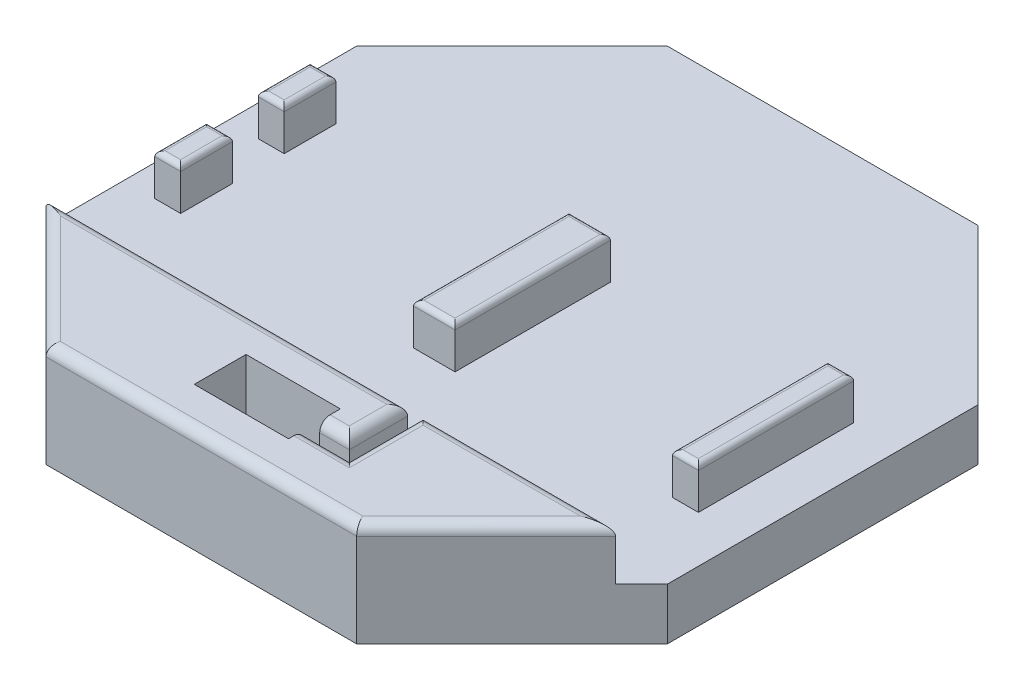
from build123d import *

# Parameters (mm, degrees)
BOSS_EXTRUDE1_DEPTH = 12.7
SKETCH2_W           = 10.16
SKETCH2_H           = 38.1
SKETCH2_W_2         = 6.35
SKETCH2_H_2         = 12.7
BOSS_EXTRUDE2_DEPTH = 10.16
BOSS_EXTRUDE3_DEPTH = 12.7
CUT_EXTRUDE1_DEPTH  = 15.24
FILLET2_R           = 2.54
FILLET4_R           = 1.27
BOSS_EXTRUDE4_DEPTH = 3.81


with BuildPart() as part:
    # Sketch1 → Boss-Extrude1 (new body)
    with BuildSketch(Plane(origin=(0, 0, 0), x_dir=(1, 0, 0), z_dir=(0, 1, 0))):
        Polygon((-38.1, 76.2), (38.1, 76.2), (76.2, 38.1), (76.2, -38.1), (38.1, -76.2), (-38.1, -76.2), (-76.2, -38.1), (-76.2, 38.1), align=None)
    extrude(amount=BOSS_EXTRUDE1_DEPTH)

    # Sketch2 → Boss-Extrude2 (add)
    with BuildSketch(Plane(origin=(0, 12.7, 0), x_dir=(1, 0, 0), z_dir=(0, 1, 0))):
        Rectangle(SKETCH2_W, SKETCH2_H)
        with Locations((61.595, 0)):
            Rectangle(SKETCH2_W_2, SKETCH2_H)
        with Locations((-65.405, 12.7)):
            Rectangle(SKETCH2_W_2, SKETCH2_H_2)
        with Locations((-65.405, -12.7)):
            Rectangle(SKETCH2_W_2, SKETCH2_H_2)
    extrude(amount=BOSS_EXTRUDE2_DEPTH)

    # Sketch4 → Boss-Extrude3 (add)
    with BuildSketch(Plane(origin=(0, 12.7, 0), x_dir=(1, 0, 0), z_dir=(0, 1, 0))):
        Polygon((-69.85, -44.45), (69.85, -44.45), (38.1, -76.2), (-38.1, -76.2), align=None)
    extrude(amount=BOSS_EXTRUDE3_DEPTH)

    # Sketch5 → Cut-Extrude1 (cut)
    with BuildSketch(Plane(origin=(0, 25.4, 0), x_dir=(1, 0, 0), z_dir=(0, 1, 0))):
        Polygon((11.557, -58.721300535), (18.829335275, -58.721300535), (18.829335275, -44.45), (22.639335275, -44.45), (22.639335275, -62.531300535), (11.557, -62.531300535), (11.557, -66.37376468), (-11.557, -66.37376468), (-11.557, -53.67376468), (11.557, -53.67376468), align=None)
    extrude(amount=-CUT_EXTRUDE1_DEPTH, mode=Mode.SUBTRACT)

    # Fillet2
    fillet2_edges = [part.edges().sort_by_distance(p)[0] for p in [
        (-53.975, 25.4, 60.325),
        (0, 25.4, 76.2),
        (53.975, 25.4, 60.325),
        (46.244667637, 25.4, 44.45),
        (-25.510332363, 25.4, 44.45),
        (17.098167637, 25.4, 62.531300535),
        (22.639335275, 25.4, 53.490650267),
        (18.829335275, 25.4, 51.585650267),
        (15.193167637, 25.4, 58.721300535),
    ]]
    fillet(fillet2_edges, radius=FILLET2_R)

    # Fillet4
    fillet4_edges = [part.edges().sort_by_distance(p)[0] for p in [
        (5.08, 22.86, 0),
        (0, 22.86, -19.05),
        (-5.08, 22.86, 0),
        (0, 22.86, 19.05),
        (58.42, 22.86, 0),
        (61.595, 22.86, 19.05),
        (64.77, 22.86, 0),
        (61.595, 22.86, -19.05),
        (-62.23, 22.86, -12.7),
        (-65.405, 22.86, -19.05),
        (-68.58, 22.86, -12.7),
        (-65.405, 22.86, -6.35),
        (-62.23, 22.86, 12.7),
        (-65.405, 22.86, 6.35),
        (-68.58, 22.86, 12.7),
        (-65.405, 22.86, 19.05),
    ]]
    fillet(fillet4_edges, radius=FILLET4_R)

    # Sketch8 → Boss-Extrude4 (add)
    with BuildSketch(Plane(origin=(18.829335275, 0, 0), x_dir=(0, 0, -1), z_dir=(1, 0, 0))):
        Polygon((-58.721300535, 10.16), (-44.45, 12.7), (-44.45, 10.16), align=None)
    extrude(amount=BOSS_EXTRUDE4_DEPTH)


solid = part.part
